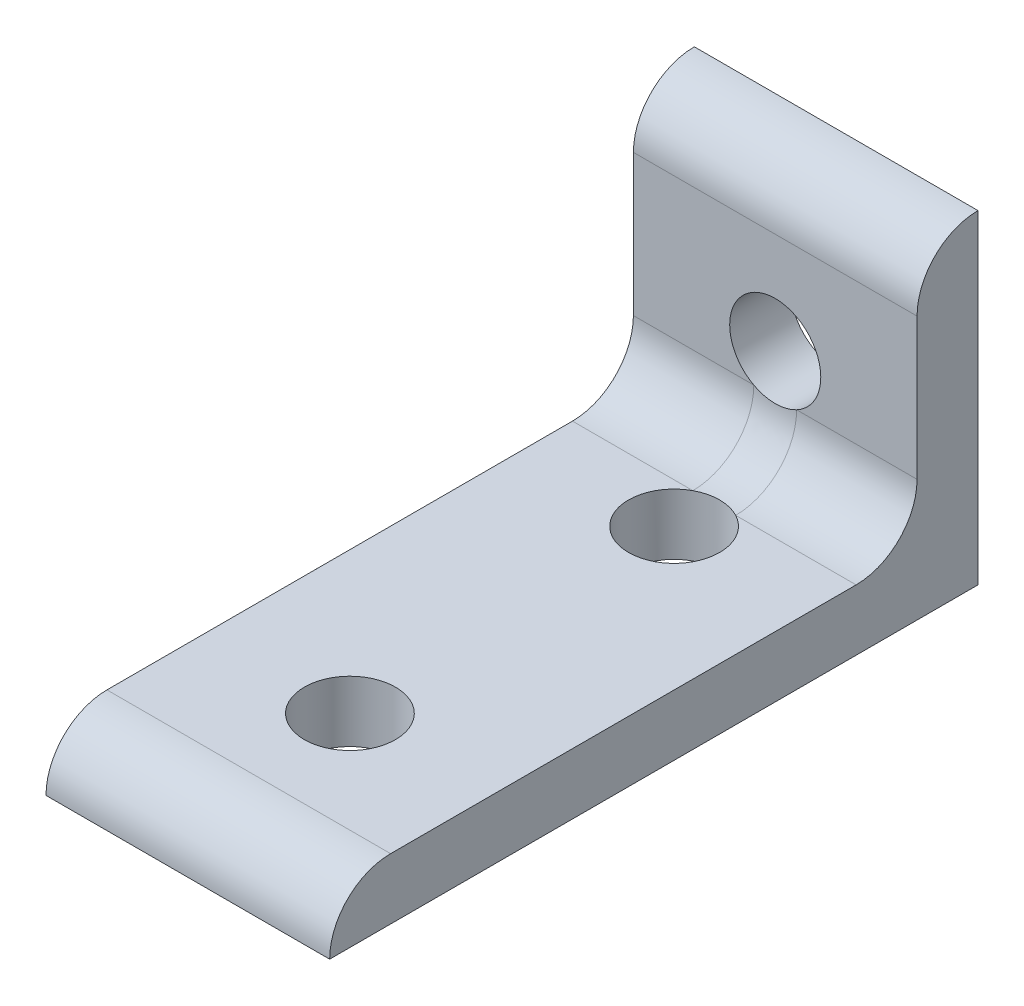
from build123d import *

# Parameters (mm, degrees)
EXTRUDE1_DEPTH     = 22.225
SKETCH2_R          = 3.5687
CUT_EXTRUDE1_DEPTH = 5.7752
FILLET1_R          = 4.7752
CUT_EXTRUDE2_DEPTH = 23.225


with BuildPart() as part:
    # Sketch1 → Extrude1 (new body)
    with BuildSketch(Plane(origin=(0, 0, 0), x_dir=(0, 0, -1), z_dir=(1, 0, 0))):
        with BuildLine():
            Line((-28.199163803, 21.897674685), (22.600836197, 21.897674685))
            Line((22.600836197, 21.897674685), (17.825636197, 26.672874685))
            Line((17.825636197, 26.672874685), (-23.423963803, 26.672874685))
            ThreePointArc((-23.423963803, 26.672874685), (-26.800540105, 25.274250987), (-28.199163803, 21.897674685))
        make_face()
    extrude(amount=EXTRUDE1_DEPTH)

    # Sketch2 → Cut-Extrude1 (cut, through all)
    with BuildSketch(Plane(origin=(0, 26.672874685, 0), x_dir=(1, 0, 0), z_dir=(0, 1, 0))):
        with Locations((11.1125, -15.499163803)):
            Circle(SKETCH2_R)
        with Locations((11.1125, 9.900836197)):
            Circle(SKETCH2_R)
    extrude(amount=-CUT_EXTRUDE1_DEPTH, mode=Mode.SUBTRACT)

    # Mirror1: part across plane


with BuildPart() as part_1:
    add(part.part)
    add(part.part.mirror(Plane(origin=(22.225, 21.897674685, -22.600836197), x_dir=(0, 0.707106781, 0.707106781), z_dir=(0, -0.707106781, 0.707106781))))

    # Fillet1
    fillet1_edges = [part_1.edges().sort_by_distance(p)[0] for p in [
        (11.1125, 26.672874685, -17.825636197),
    ]]
    fillet(fillet1_edges, radius=FILLET1_R)

    # Sketch3 → Cut-Extrude2 (cut, through all)
    with BuildSketch(Plane(origin=(22.225, 0, 0), x_dir=(0, 0, -1), z_dir=(1, 0, 0))):
        with BuildLine():
            Line((17.825636197, 67.922474685), (17.825636197, 42.522474685))
            ThreePointArc((17.825636197, 42.522474685), (19.224259895, 45.899050987), (22.600836197, 47.297674685))
            Line((22.600836197, 47.297674685), (22.600836197, 72.697674685))
            ThreePointArc((22.600836197, 72.697674685), (19.224259895, 71.299050987), (17.825636197, 67.922474685))
        make_face()
    extrude(amount=-CUT_EXTRUDE2_DEPTH, mode=Mode.SUBTRACT)


solid = part_1.part
